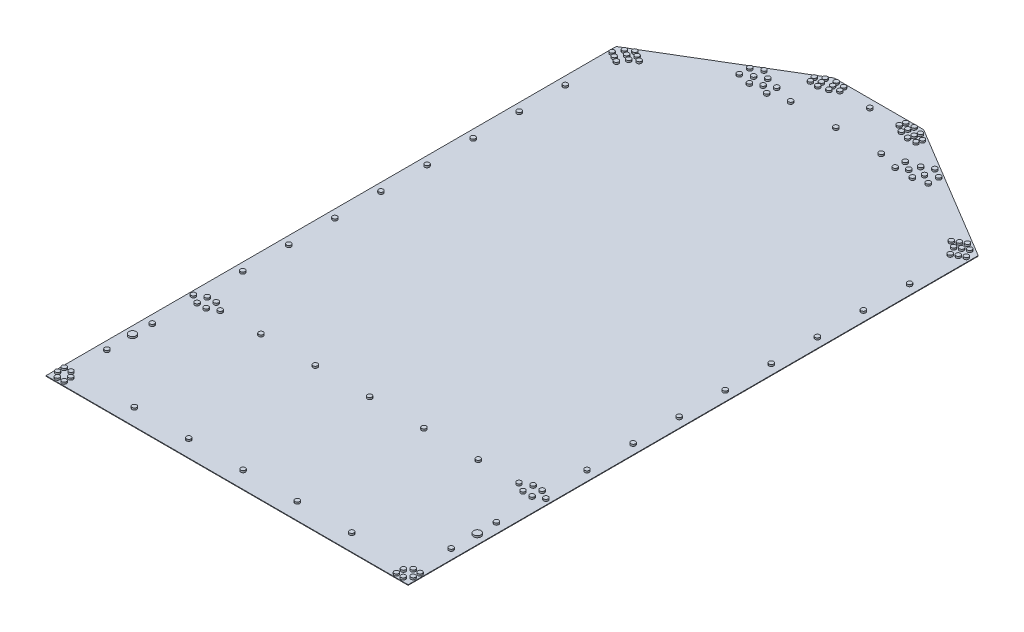
from build123d import *

# Parameters (mm, degrees)
BOSS_EXTRUDE1_DEPTH = 1.6256
FILLET1_R           = 4.191
FILLET2_R           = 4.191
SKETCH2_R           = 6.4262
SKETCH2_R_2         = 10.287
BOSS_EXTRUDE2_DEPTH = 5.08


with BuildPart() as part:
    # Sketch1 → Boss-Extrude1 (new body)
    with BuildSketch(Plane(origin=(0, 0, 0), x_dir=(1, 0, 0), z_dir=(0, 1, 0))):
        Polygon((-125.4125, 0), (125.4125, 0), (508, -229.417072782), (508, -1828.8), (-508, -1828.8), (-508, -229.417072782), align=None)
    extrude(amount=BOSS_EXTRUDE1_DEPTH)

    # Fillet1
    fillet1_edges = [part.edges().sort_by_distance(p)[0] for p in [
        (508, 0.8128, 229.417072782),
        (-508, 0.8128, 229.417072782),
    ]]
    fillet(fillet1_edges, radius=FILLET1_R)

    # Fillet2
    fillet2_edges = [part.edges().sort_by_distance(p)[0] for p in [
        (-125.4125, 0.8128, 0),
        (125.4125, 0.8128, 0),
    ]]
    fillet(fillet2_edges, radius=FILLET2_R)

    # Sketch2 → Boss-Extrude2 (add)
    with BuildSketch(Plane(origin=(0, 1.6256, 0), x_dir=(1, 0, 0), z_dir=(0, 1, 0))):
        with Locations((-304.8, -1783.9436)):
            Circle(SKETCH2_R)
        with Locations((-152.4, -1783.9436)):
            Circle(SKETCH2_R)
        with Locations((0, -1783.9436)):
            Circle(SKETCH2_R)
        with Locations((152.4, -1783.9436)):
            Circle(SKETCH2_R)
        with Locations((304.8, -1783.9436)):
            Circle(SKETCH2_R)
        with Locations((-304.8, -1428.9024)):
            Circle(SKETCH2_R)
        with Locations((-152.4, -1428.9024)):
            Circle(SKETCH2_R)
        with Locations((0, -1428.9024)):
            Circle(SKETCH2_R)
        with Locations((152.4, -1428.9024)):
            Circle(SKETCH2_R)
        with Locations((304.8, -1428.9024)):
            Circle(SKETCH2_R)
        with Locations((-482.9048, -1301.9024)):
            Circle(SKETCH2_R)
        with Locations((-482.9048, -1172.6418)):
            Circle(SKETCH2_R)
        with Locations((-482.9048, -1043.3812)):
            Circle(SKETCH2_R)
        with Locations((-482.9048, -914.1206)):
            Circle(SKETCH2_R)
        with Locations((-482.9048, -784.86)):
            Circle(SKETCH2_R)
        with Locations((-482.9048, -655.5994)):
            Circle(SKETCH2_R)
        with Locations((-482.9048, -526.3388)):
            Circle(SKETCH2_R)
        with Locations((-482.9048, -397.0782)):
            Circle(SKETCH2_R)
        with Locations((482.9048, -1301.9024)):
            Circle(SKETCH2_R)
        with Locations((482.9048, -1172.6418)):
            Circle(SKETCH2_R)
        with Locations((482.9048, -1043.3812)):
            Circle(SKETCH2_R)
        with Locations((482.9048, -914.1206)):
            Circle(SKETCH2_R)
        with Locations((482.9048, -784.86)):
            Circle(SKETCH2_R)
        with Locations((482.9048, -655.5994)):
            Circle(SKETCH2_R)
        with Locations((482.9048, -526.3388)):
            Circle(SKETCH2_R)
        with Locations((482.9048, -397.0782)):
            Circle(SKETCH2_R)
        with Locations((444.5, -1414.7546)):
            Circle(SKETCH2_R)
        with Locations((469.9, -1414.7546)):
            Circle(SKETCH2_R)
        with Locations((444.5, -1443.0502)):
            Circle(SKETCH2_R)
        with Locations((469.9, -1443.0502)):
            Circle(SKETCH2_R)
        with Locations((-469.9, -1414.7546)):
            Circle(SKETCH2_R)
        with Locations((-444.5, -1414.7546)):
            Circle(SKETCH2_R)
        with Locations((-469.9, -1443.0502)):
            Circle(SKETCH2_R)
        with Locations((-444.5, -1443.0502)):
            Circle(SKETCH2_R)
        with Locations((419.1, -1428.9024)):
            Circle(SKETCH2_R)
        with Locations((0, -25.4)):
            Circle(SKETCH2_R)
        with Locations((494.411, -1428.9024)):
            Circle(SKETCH2_R)
        with Locations((-494.411, -1428.9024)):
            Circle(SKETCH2_R)
        with Locations((-419.1, -1428.9024)):
            Circle(SKETCH2_R)
        with Locations((466.09, -1819.783)):
            Circle(SKETCH2_R)
        with Locations((466.852, -1800.7838)):
            Circle(SKETCH2_R)
        with Locations((485.14, -1819.783)):
            Circle(SKETCH2_R)
        with Locations((498.729, -1805.6352)):
            Circle(SKETCH2_R)
        with Locations((480.06, -1786.5852)):
            Circle(SKETCH2_R)
        with Locations((499.11, -1786.5852)):
            Circle(SKETCH2_R)
        with Locations((-466.852, -1800.7838)):
            Circle(SKETCH2_R)
        with Locations((-466.09, -1819.783)):
            Circle(SKETCH2_R)
        with Locations((-485.14, -1819.783)):
            Circle(SKETCH2_R)
        with Locations((-498.729, -1805.6352)):
            Circle(SKETCH2_R)
        with Locations((-499.11, -1786.5852)):
            Circle(SKETCH2_R)
        with Locations((-480.06, -1786.5852)):
            Circle(SKETCH2_R)
        with Locations((482.9048, -1555.9024)):
            Circle(SKETCH2_R)
        with Locations((482.9048, -1682.9024)):
            Circle(SKETCH2_R)
        with Locations((-482.9048, -1682.9024)):
            Circle(SKETCH2_R)
        with Locations((-482.9048, -1555.9024)):
            Circle(SKETCH2_R)
        with Locations((468.405641167, -268.223259436)):
            Circle(SKETCH2_R)
        with Locations((482.703720584, -259.968259436)):
            Circle(SKETCH2_R)
        with Locations((497.0018, -251.713259436)):
            Circle(SKETCH2_R)
        with Locations((455.705641167, -246.22621418)):
            Circle(SKETCH2_R)
        with Locations((470.003720584, -237.97121418)):
            Circle(SKETCH2_R)
        with Locations((484.3018, -229.71621418)):
            Circle(SKETCH2_R)
        with Locations((437.94528149, -234.659093726)):
            Circle(SKETCH2_R)
        with Locations((452.243360907, -226.404093726)):
            Circle(SKETCH2_R)
        with Locations((466.541440323, -218.149093726)):
            Circle(SKETCH2_R)
        with Locations((-228.666749782, -134.62)):
            Circle(SKETCH2_R)
        with Locations((-265.017930404, -126.492)):
            Circle(SKETCH2_R)
        with Locations((-265.017930404, -97.282)):
            Circle(SKETCH2_R)
        with Locations((-239.721328359, -111.887)):
            Circle(SKETCH2_R)
        with Locations((-239.721328359, -82.677)):
            Circle(SKETCH2_R)
        with Locations((-214.424726315, -97.282)):
            Circle(SKETCH2_R)
        with Locations((-180.273250218, -134.62)):
            Circle(SKETCH2_R)
        with Locations((-180.273250218, -106.68)):
            Circle(SKETCH2_R)
        with Locations((-204.47, -120.65)):
            Circle(SKETCH2_R)
        with Locations((0, -120.65)):
            Circle(SKETCH2_R)
        with Locations((-127, -120.65)):
            Circle(SKETCH2_R)
        with Locations((127, -120.65)):
            Circle(SKETCH2_R)
        with Locations((204.47, -120.65)):
            Circle(SKETCH2_R)
        with Locations((180.273250218, -106.68)):
            Circle(SKETCH2_R)
        with Locations((180.273250218, -134.62)):
            Circle(SKETCH2_R)
        with Locations((214.424726315, -97.282)):
            Circle(SKETCH2_R)
        with Locations((239.721328359, -82.677)):
            Circle(SKETCH2_R)
        with Locations((239.721328359, -111.887)):
            Circle(SKETCH2_R)
        with Locations((265.017930404, -97.282)):
            Circle(SKETCH2_R)
        with Locations((265.017930404, -126.492)):
            Circle(SKETCH2_R)
        with Locations((228.666749782, -134.62)):
            Circle(SKETCH2_R)
        with Locations((-466.541440323, -218.149093726)):
            Circle(SKETCH2_R)
        with Locations((-452.243360907, -226.404093726)):
            Circle(SKETCH2_R)
        with Locations((-437.94528149, -234.659093726)):
            Circle(SKETCH2_R)
        with Locations((-484.3018, -229.71621418)):
            Circle(SKETCH2_R)
        with Locations((-470.003720584, -237.97121418)):
            Circle(SKETCH2_R)
        with Locations((-455.705641167, -246.22621418)):
            Circle(SKETCH2_R)
        with Locations((-497.0018, -251.713259436)):
            Circle(SKETCH2_R)
        with Locations((-482.703720584, -259.968259436)):
            Circle(SKETCH2_R)
        with Locations((-468.405641167, -268.223259436)):
            Circle(SKETCH2_R)
        with Locations((129.911816421, -31.34756384)):
            Circle(SKETCH2_R)
        with Locations((133.808549357, -17.272)):
            Circle(SKETCH2_R)
        with Locations((126.015083486, -45.423127681)):
            Circle(SKETCH2_R)
        with Locations((151.950103205, -29.805663829)):
            Circle(SKETCH2_R)
        with Locations((148.019485635, -44.003623877)):
            Circle(SKETCH2_R)
        with Locations((83.394288176, -26.112537007)):
            Circle(SKETCH2_R)
        with Locations((87.324905746, -11.914576959)):
            Circle(SKETCH2_R)
        with Locations((105.43257496, -24.570636996)):
            Circle(SKETCH2_R)
        with Locations((101.535842024, -38.646200836)):
            Circle(SKETCH2_R)
        with Locations((109.329307895, -10.495073155)):
            Circle(SKETCH2_R)
        with Locations((-109.329307895, -10.495073155)):
            Circle(SKETCH2_R)
        with Locations((-101.535842024, -38.646200836)):
            Circle(SKETCH2_R)
        with Locations((-105.43257496, -24.570636996)):
            Circle(SKETCH2_R)
        with Locations((-87.324905746, -11.914576959)):
            Circle(SKETCH2_R)
        with Locations((-83.394288176, -26.112537007)):
            Circle(SKETCH2_R)
        with Locations((-148.019485635, -44.003623877)):
            Circle(SKETCH2_R)
        with Locations((-151.950103205, -29.805663829)):
            Circle(SKETCH2_R)
        with Locations((-126.015083486, -45.423127681)):
            Circle(SKETCH2_R)
        with Locations((-133.808549357, -17.272)):
            Circle(SKETCH2_R)
        with Locations((-129.911816421, -31.34756384)):
            Circle(SKETCH2_R)
        with Locations((483.743, -1610.487)):
            Circle(SKETCH2_R_2)
        with Locations((-483.743, -1610.487)):
            Circle(SKETCH2_R_2)
    extrude(amount=BOSS_EXTRUDE2_DEPTH)


solid = part.part
